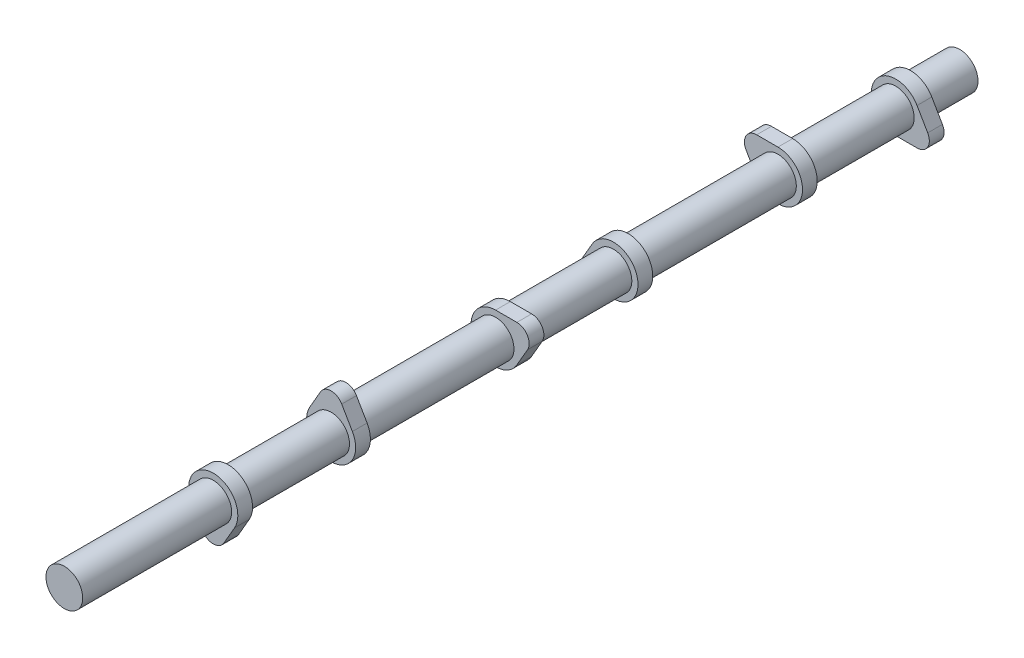
from build123d import *

# Parameters (mm, degrees)
ESTRUSIONE_ESTRUSIONE1_DEPTH = 7.62
CORPO_SPOSTA_COPIA8_ANGLE    = 180
ESTRUSIONE_ESTRUSIONE4_START = -25.4
SCHIZZO11_R                  = 9.5
ESTRUSIONE_ESTRUSIONE4_DEPTH = 146.05
RIPETIZIONE_A_L1_COUNT       = 3
RIPETIZIONE_A_L1_PITCH       = 146.05
CORPO_SPOSTA_COPIA9_ANGLE    = 120
CORPO_SPOSTA_COPIA10_ANGLE   = 120
SCHIZZO12_R                  = 9.5
ESTRUSIONE_ESTRUSIONE5_DEPTH = 24.97


with BuildPart() as part:
    # Schizzo4 → Estrusione-Estrusione1 (new body)
    with BuildSketch(Plane.XY):
        with BuildLine():
            Line((5.499261314, 15.875), (10.998522628, 6.35))
            ThreePointArc((10.998522628, 6.35), (0, -12.7), (-10.998522628, 6.35))
            Line((-10.998522628, 6.35), (-5.499261314, 15.875))
            ThreePointArc((-5.499261314, 15.875), (0, 19.05), (5.499261314, 15.875))
        make_face()
    extrude(amount=ESTRUSIONE_ESTRUSIONE1_DEPTH)


with BuildPart() as body_2:
    # Corpo-Sposta_copia7: copy of part
    add(part.part.moved(Location((0, 0, 60.96))))


with BuildPart() as body_2_1:
    # Corpo-Sposta_copia8: moved
    add(body_2.part.rotate(Axis((0, 0, 0), (0, 0, 1)), CORPO_SPOSTA_COPIA8_ANGLE))


with BuildPart() as part_1:
    add(part.part)

    add(body_2_1.part)  # Estrusione-Estrusione4 merges body 2
    # Schizzo11 → Estrusione-Estrusione4 (add)
    with BuildSketch(Plane.XY.offset(ESTRUSIONE_ESTRUSIONE4_START)):
        Circle(SCHIZZO11_R)
    extrude(amount=ESTRUSIONE_ESTRUSIONE4_DEPTH)


with BuildPart() as ripetizione_a_l1_1:
    # Ripetizione a L1: pattern copy
    add(part_1.part.moved(Location(Vector(0, 0, -1) * (1 * RIPETIZIONE_A_L1_PITCH))))


with BuildPart() as ripetizione_a_l1_2:
    # Ripetizione a L1: pattern copy
    add(part_1.part.moved(Location(Vector(0, 0, -1) * (2 * RIPETIZIONE_A_L1_PITCH))))


with BuildPart() as ripetizione_a_l1_1_1:
    # Corpo-Sposta_copia9: moved
    add(ripetizione_a_l1_1.part.rotate(Axis((0, 0, 0), (0, 0, 1)), CORPO_SPOSTA_COPIA9_ANGLE))


with BuildPart() as ripetizione_a_l1_2_1:
    # Corpo-Sposta_copia10: moved
    add(ripetizione_a_l1_2.part.rotate(Axis((0, 0, 0), (0, 0, -1)), CORPO_SPOSTA_COPIA10_ANGLE))


with BuildPart() as part_2:
    add(part_1.part)

    # Schizzo12 → Estrusione-Estrusione5 (add)
    with BuildSketch(Plane.XY.offset(120.65)):
        Circle(SCHIZZO12_R)
    extrude(amount=ESTRUSIONE_ESTRUSIONE5_DEPTH)


with BuildPart() as ripetizione_a_l1_2_2:
    add(ripetizione_a_l1_2_1.part)

    # Abbina1: union Ripetizione a L1_1, part
    add(ripetizione_a_l1_1_1.part)
    add(part_2.part)


solid = ripetizione_a_l1_2_2.part
